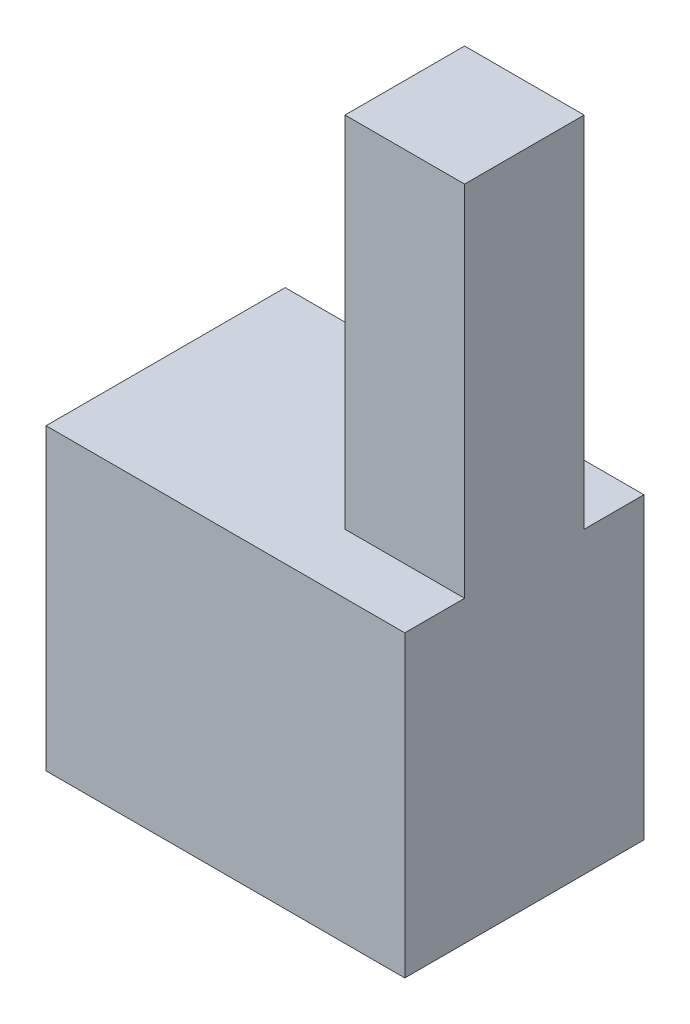
from build123d import *

# Parameters (mm, degrees)
BOSS_EXTRUDE3_DEPTH = 10
SKETCH5_W           = 30
SKETCH5_H           = 25
BOSS_EXTRUDE5_DEPTH = 5
BOSS_EXTRUDE7_DEPTH = 5


with BuildPart() as part:
    # Sketch3 → Boss-Extrude3 (new body)
    with BuildSketch(Plane.XY):
        Polygon((0, 0), (0, -5), (20, -5), (20, -25), (30, -25), (30, 30), (20, 30), (20, 0), align=None)
    extrude(amount=BOSS_EXTRUDE3_DEPTH)

    # Sketch5 → Boss-Extrude5 (add)
    with BuildSketch(Plane.XY.offset(10)):
        with Locations((15, -12.5)):
            Rectangle(SKETCH5_W, SKETCH5_H)
    extrude(amount=BOSS_EXTRUDE5_DEPTH)

    # Sketch7 → Boss-Extrude7 (add)
    with BuildSketch(Plane(origin=(0, 0, 0), x_dir=(-1, 0, 0), z_dir=(0, 0, -1))):
        Polygon((0, 0), (-20, 0), (-20.758888401, 0), (-30, 0), (-30, -25), (-20, -25), (-20, -5), (0, -5), align=None)
    extrude(amount=BOSS_EXTRUDE7_DEPTH)


solid = part.part
